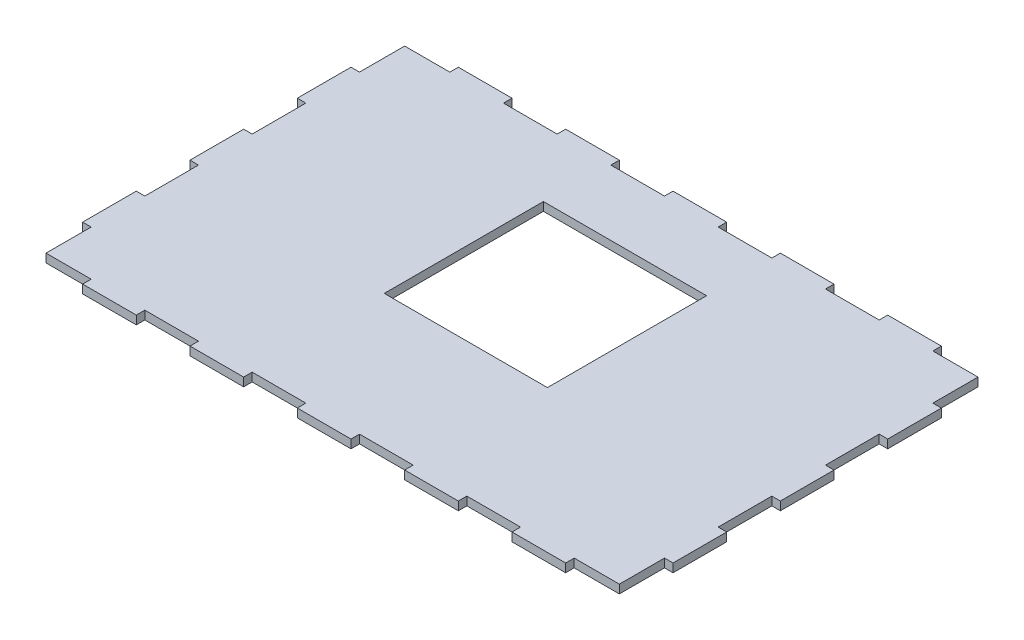
from build123d import *

# Parameters (mm, degrees)
SKETCH40_W          = 220
SKETCH40_H          = 140
BOSS_EXTRUDE7_DEPTH = 3.175
SKETCH41_W          = 20
SKETCH41_H          = 3.175
SKETCH41_W_2        = 3.175
SKETCH41_H_2        = 20
CUT_EXTRUDE21_DEPTH = 3.175
SKETCH53_W          = 60.8
SKETCH53_H          = 59.3
CUT_EXTRUDE26_DEPTH = 3.175


with BuildPart() as part:
    # Sketch40 → Boss-Extrude7 (new body)
    with BuildSketch(Plane(origin=(0, 0, 0), x_dir=(1, 0, 0), z_dir=(0, 1, 0))):
        with Locations((-4.2e-06, -668.101928689)):
            Rectangle(SKETCH40_W, SKETCH40_H)
    extrude(amount=BOSS_EXTRUDE7_DEPTH)

    # Sketch41 → Cut-Extrude21 (cut)
    with BuildSketch(Plane(origin=(0, 3.175, 0), x_dir=(1, 0, 0), z_dir=(0, 1, 0))):
        with Locations((59.9999958, -736.514428689)):
            Rectangle(SKETCH41_W, SKETCH41_H)
        Polygon((109.9999958, -738.101928689), (89.9999958, -738.101928689), (89.9999958, -734.926928689), (106.8249958, -734.926928689), (106.8249958, -718.101928689), (109.9999958, -718.101928689), align=None)
        with Locations((19.9999958, -736.514428689)):
            Rectangle(SKETCH41_W, SKETCH41_H)
        with Locations((-20.0000042, -736.514428689)):
            Rectangle(SKETCH41_W, SKETCH41_H)
        with Locations((-60.0000042, -736.514428689)):
            Rectangle(SKETCH41_W, SKETCH41_H)
        Polygon((-90.0000042, -738.101928689), (-90.0000042, -734.926928689), (-106.8250042, -734.926928689), (-106.8250042, -718.101928689), (-110.0000042, -718.101928689), (-110.0000042, -738.101928689), align=None)
        with Locations((59.9999958, -599.689428689)):
            Rectangle(SKETCH41_W, SKETCH41_H)
        Polygon((109.9999958, -598.101928689), (89.9999958, -598.101928689), (89.9999958, -601.276928689), (106.8249958, -601.276928689), (106.8249958, -618.101928689), (109.9999958, -618.101928689), align=None)
        with Locations((19.9999958, -599.689428689)):
            Rectangle(SKETCH41_W, SKETCH41_H)
        with Locations((-20.0000042, -599.689428689)):
            Rectangle(SKETCH41_W, SKETCH41_H)
        with Locations((-60.0000042, -599.689428689)):
            Rectangle(SKETCH41_W, SKETCH41_H)
        Polygon((-90.0000042, -598.101928689), (-90.0000042, -601.276928689), (-106.8250042, -601.276928689), (-106.8250042, -618.101928689), (-110.0000042, -618.101928689), (-110.0000042, -598.101928689), align=None)
        with Locations((108.4124958, -648.101928689)):
            Rectangle(SKETCH41_W_2, SKETCH41_H_2)
        with Locations((108.4124958, -688.101928689)):
            Rectangle(SKETCH41_W_2, SKETCH41_H_2)
        with Locations((-108.4125042, -648.101928689)):
            Rectangle(SKETCH41_W_2, SKETCH41_H_2)
        with Locations((-108.4125042, -688.101928689)):
            Rectangle(SKETCH41_W_2, SKETCH41_H_2)
    extrude(amount=-CUT_EXTRUDE21_DEPTH, mode=Mode.SUBTRACT)

    # Sketch53 → Cut-Extrude26 (cut)
    with BuildSketch(Plane(origin=(0, 3.175, 0), x_dir=(1, 0, 0), z_dir=(0, 1, 0))):
        with Locations((-0.4, -655.251928689)):
            Rectangle(SKETCH53_W, SKETCH53_H)
    extrude(amount=-CUT_EXTRUDE26_DEPTH, mode=Mode.SUBTRACT)


solid = part.part
